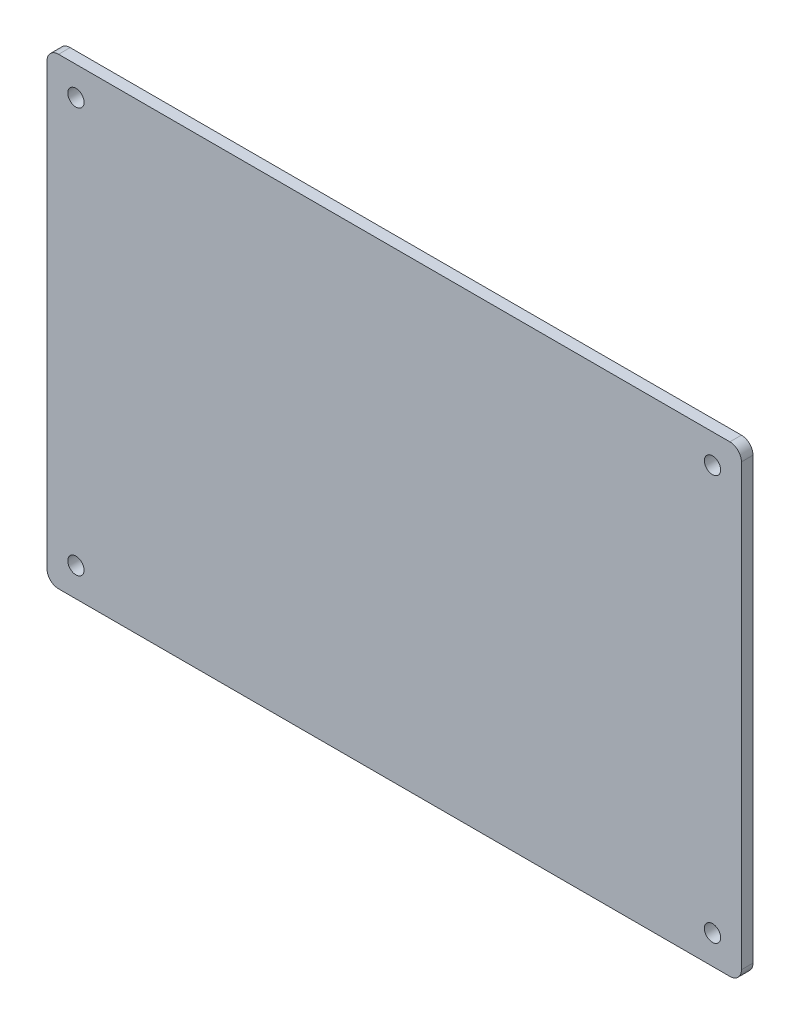
from build123d import *

# Parameters (mm, degrees)
ESQUISSE1_W             = 120
ESQUISSE1_H             = 80
BOSS_EXTRU_1_DEPTH      = 2
CONG_4_R                = 2
CONG_5_R                = 2
ESQUISSE2_R             = 1.407340655
ENL_V_MAT_EXTRU_1_DEPTH = 3


with BuildPart() as part:
    # Esquisse1 → Boss.-Extru.1 (new body)
    with BuildSketch(Plane.XY):
        with Locations((60, 40)):
            Rectangle(ESQUISSE1_W, ESQUISSE1_H)
    extrude(amount=BOSS_EXTRU_1_DEPTH)

    # Congé4
    cong_4_edges = [part.edges().sort_by_distance(p)[0] for p in [
        (0, 0, 1),
    ]]
    fillet(cong_4_edges, radius=CONG_4_R)

    # Congé5
    cong_5_edges = [part.edges().sort_by_distance(p)[0] for p in [
        (0, 80, 1),
        (120, 80, 1),
        (120, 0, 1),
    ]]
    fillet(cong_5_edges, radius=CONG_5_R)

    # Esquisse2 → Enlèv. mat.-Extru.1 (cut, through all)
    with BuildSketch(Plane.XY):
        with Locations((5, 75)):
            Circle(ESQUISSE2_R)
        with Locations((5, 5)):
            Circle(ESQUISSE2_R)
        with Locations((115, 5)):
            Circle(ESQUISSE2_R)
        with Locations((115, 75)):
            Circle(ESQUISSE2_R)
    extrude(amount=ENL_V_MAT_EXTRU_1_DEPTH, mode=Mode.SUBTRACT)


solid = part.part
